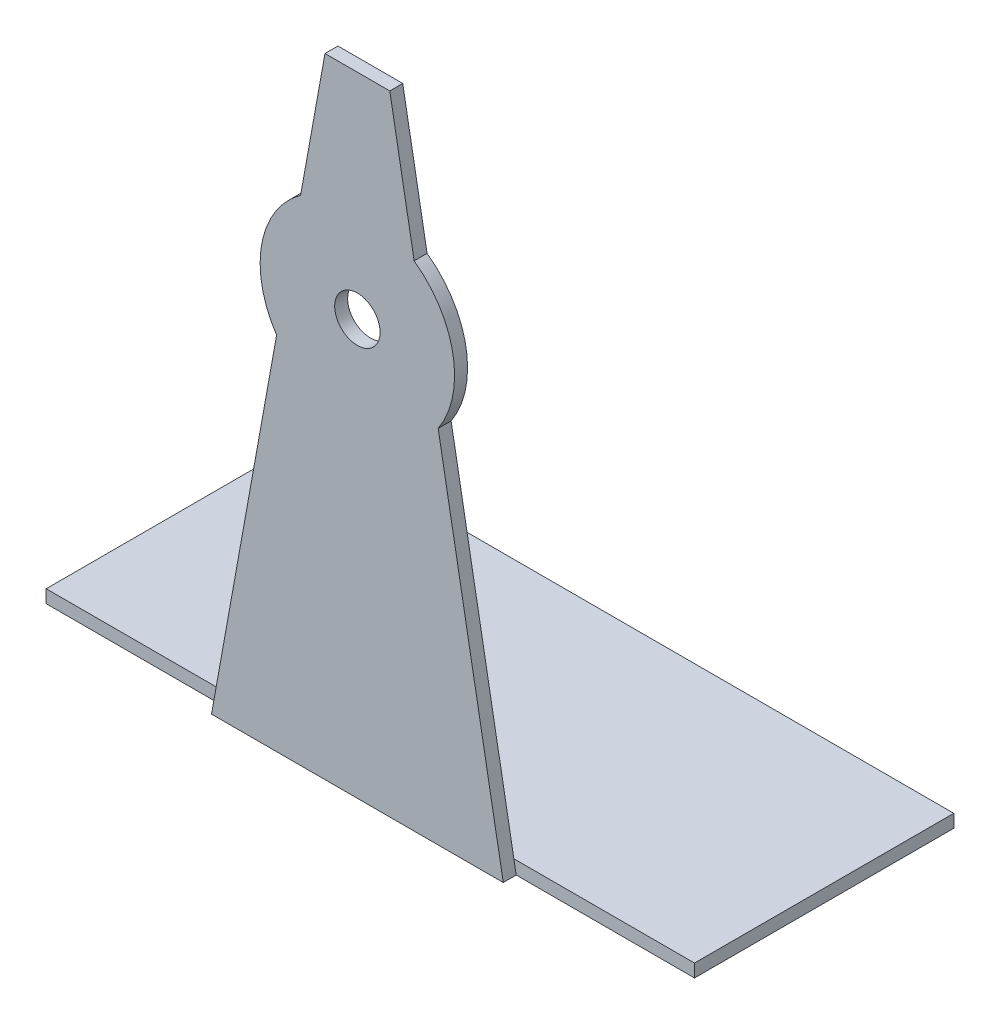
from build123d import *

# Parameters (mm, degrees)
SKETCH_1_W          = 100
SKETCH_1_H          = 40
EXTRUDE_1_DEPTH     = 2
EXTRUDE_2_DEPTH     = 2
SKETCH_4_R          = 3.5
CUT_EXTRUDE_1_DEPTH = 2


with BuildPart() as part:
    # 草图1 → 凸台-拉伸1 (new body)
    with BuildSketch(Plane(origin=(0, 0, 0), x_dir=(1, 0, 0), z_dir=(0, 1, 0))):
        with Locations((50, 20)):
            Rectangle(SKETCH_1_W, SKETCH_1_H)
    extrude(amount=EXTRUDE_1_DEPTH)

    # 草图3 → 凸台-拉伸2 (add)
    with BuildSketch(Plane.XY):
        with BuildLine():
            Line((72.5, 0), (27.5, 0))
            Line((27.5, 0), (37.539738947, 55.648838734))
            ThreePointArc((37.539738947, 55.648838734), (35.238312644, 66.663191018), (41.243617117, 76.178906306))
            Line((41.243617117, 76.178906306), (45, 97))
            Line((45, 97), (55, 97))
            Line((55, 97), (58.756382883, 76.178906306))
            ThreePointArc((58.756382883, 76.178906306), (64.761687356, 66.663191018), (62.460261053, 55.648838734))
            Line((62.460261053, 55.648838734), (72.5, 0))
        make_face()
    extrude(amount=EXTRUDE_2_DEPTH)

    # 草图4 → 切除-拉伸1 (cut)
    with BuildSketch(Plane.XY.offset(2)):
        with Locations((50, 64)):
            Circle(SKETCH_4_R)
    extrude(amount=-CUT_EXTRUDE_1_DEPTH, mode=Mode.SUBTRACT)


solid = part.part
